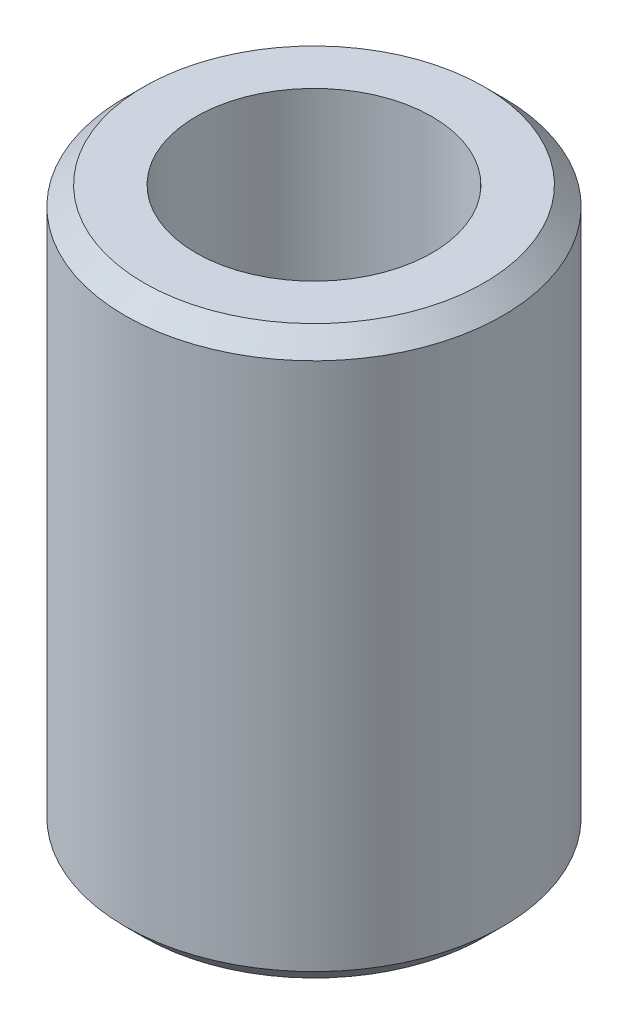
from build123d import *

# Parameters (mm, degrees)
SKETCH1_R           = 20
SKETCH1_R_2         = 12.5
BOSS_EXTRUDE1_DEPTH = 30
CHAMFER1_SIZE       = 2


with BuildPart() as part:
    # Sketch1 → Boss-Extrude1 (new body, symmetric)
    with BuildSketch(Plane(origin=(0, 0, 0), x_dir=(1, 0, 0), z_dir=(0, 1, 0))):
        Circle(SKETCH1_R)
        Circle(SKETCH1_R_2, mode=Mode.SUBTRACT)
    extrude(amount=BOSS_EXTRUDE1_DEPTH, both=True)

    # Chamfer1
    chamfer1_edges = [part.edges().sort_by_distance(p)[0] for p in [
        (-20, -30, 0),
        (-20, 30, 0),
    ]]
    chamfer(chamfer1_edges, length=CHAMFER1_SIZE)


solid = part.part
